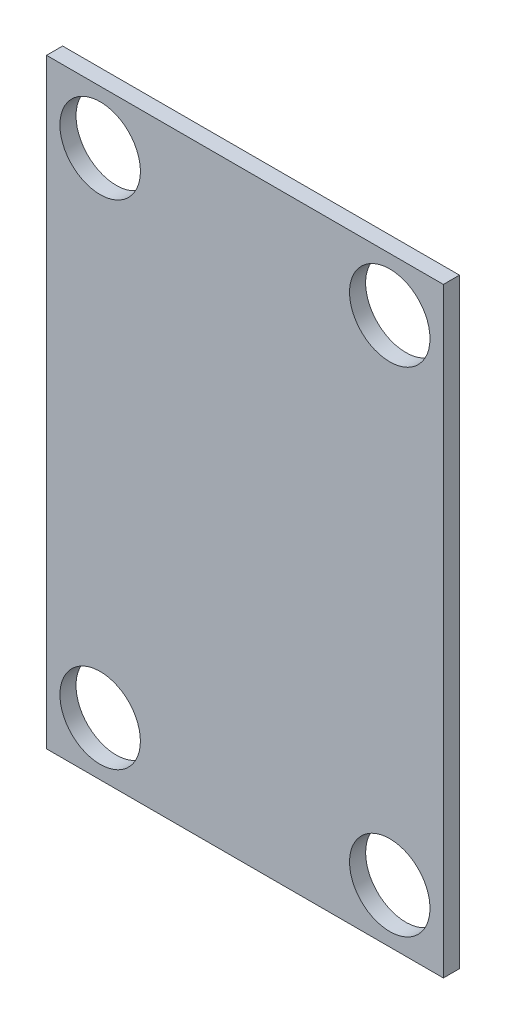
from build123d import *

# Parameters (mm, degrees)
SKETCH_3_W      = 37
SKETCH_3_H      = 56
SKETCH_3_R      = 3.75
EXTRUDE_1_DEPTH = 1.5


with BuildPart() as part:
    # Эскиз3 → Бобышка-Вытянуть1 (new body)
    with BuildSketch(Plane.XY):
        with Locations((-0.540511526, 0)):
            Rectangle(SKETCH_3_W, SKETCH_3_H)
        with Locations((-14.040511526, 23)):
            Circle(SKETCH_3_R, mode=Mode.SUBTRACT)
        with Locations((-14.040511526, -23)):
            Circle(SKETCH_3_R, mode=Mode.SUBTRACT)
        with Locations((12.959488474, 23)):
            Circle(SKETCH_3_R, mode=Mode.SUBTRACT)
        with Locations((12.959488474, -23)):
            Circle(SKETCH_3_R, mode=Mode.SUBTRACT)
    extrude(amount=EXTRUDE_1_DEPTH)


solid = part.part
